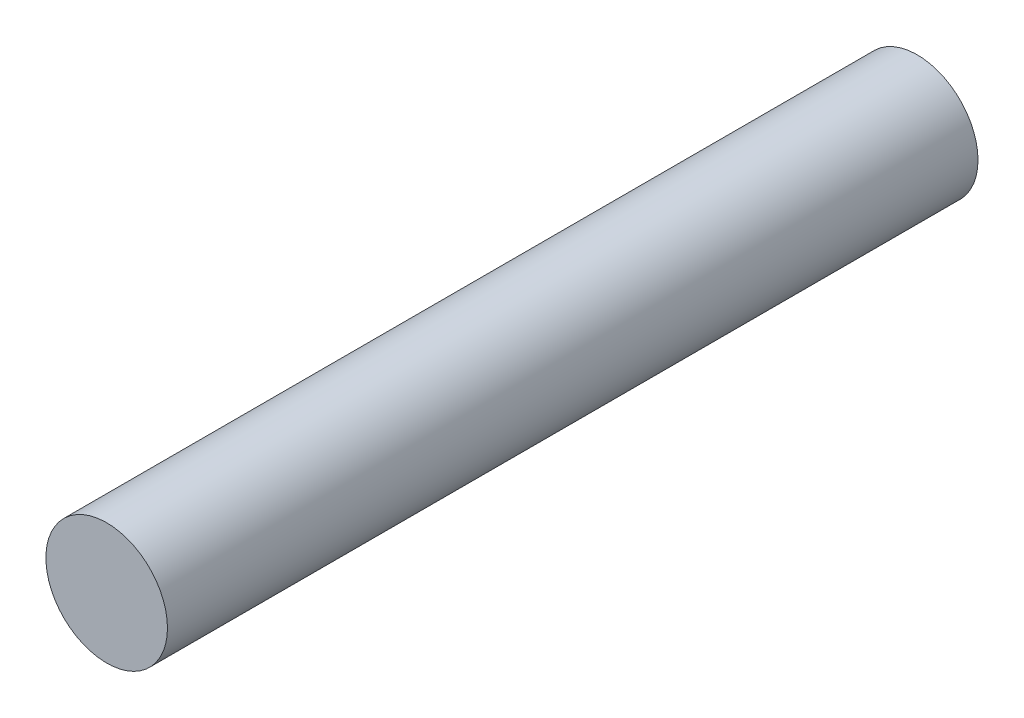
from build123d import *

# Parameters (mm, degrees)
SKETCH1_R           = 3
BOSS_EXTRUDE1_DEPTH = 40


with BuildPart() as part:
    # Sketch1 → Boss-Extrude1 (new body)
    with BuildSketch(Plane.XY):
        with Locations((-13.467951043, 10.061038526)):
            Circle(SKETCH1_R)
    extrude(amount=BOSS_EXTRUDE1_DEPTH)


solid = part.part
